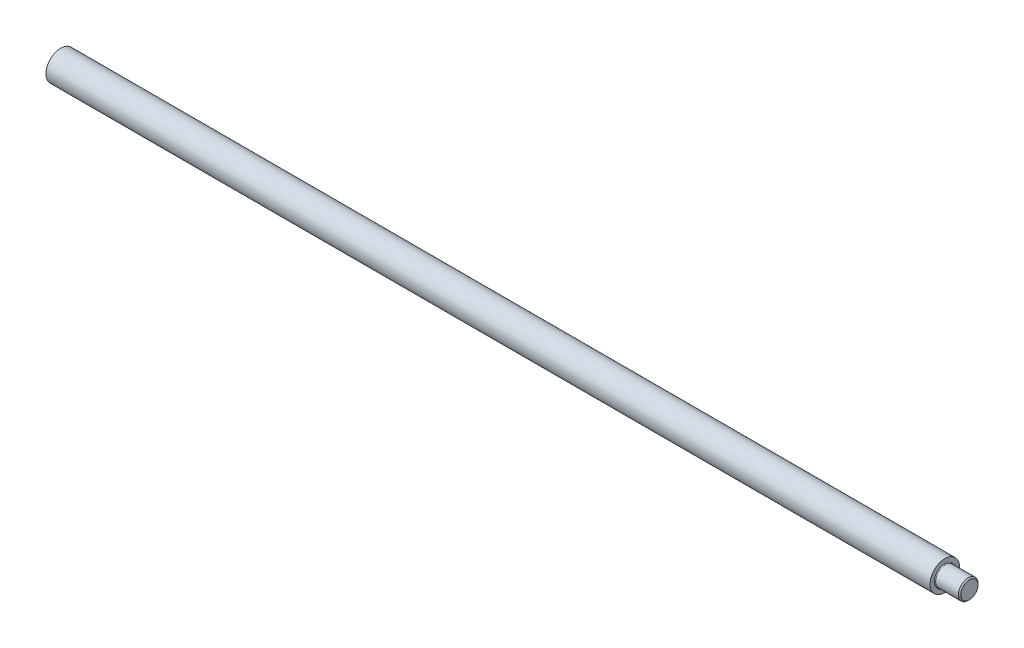
from build123d import *


with BuildPart() as part:
    # Sketch1 → Revolve1 (revolve)
    with BuildSketch(Plane.XY):
        with BuildLine():
            Line((10, 5.684210526), (10, 0))
            Line((10, 0), (360, 0))
            Line((360, 0), (360, 3.315789474))
            Line((360, 3.315789474), (359.526315789, 3.789473684))
            Line((359.526315789, 3.789473684), (350.810526316, 3.789473684))
            ThreePointArc((350.810526316, 3.789473684), (350.609559125, 3.87271702), (350.526315789, 4.073684211))
            Line((350.526315789, 4.073684211), (350.526315789, 5.684210526))
            Line((350.526315789, 5.684210526), (10, 5.684210526))
        make_face()
    revolve(axis=Axis((10, 0, 0), (1, 0, 0)))


solid = part.part
